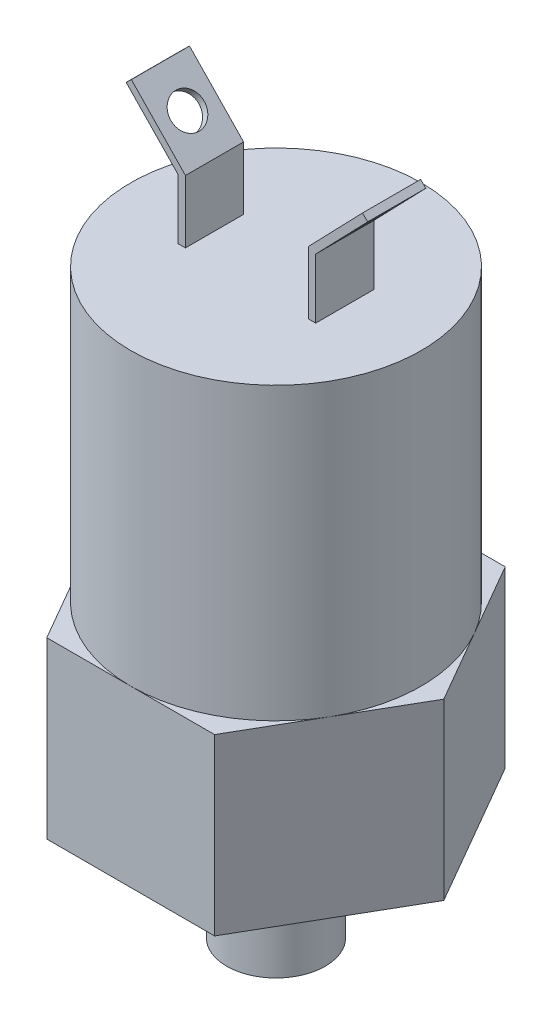
from build123d import *

# Parameters (mm, degrees)
BOSS_EXTRUDE1_DEPTH = 15.24
SKETCH3_R           = 12.7
BOSS_EXTRUDE2_DEPTH = 25.4
SKETCH4_R           = 4.3053
BOSS_EXTRUDE3_DEPTH = 10.16
EXTRUDE_THIN1_DEPTH = 2.54
CUT_EXTRUDE1_REACH  = 50.698
SKETCH6_R           = 1.4605


with BuildPart() as part:
    # Sketch2 → Boss-Extrude1 (new body)
    with BuildSketch(Plane(origin=(0, 0, 0), x_dir=(1, 0, 0), z_dir=(0, 1, 0))):
        Polygon((7.332348419, 12.7), (-7.332348419, 12.7), (-14.664696837, 0), (-7.332348419, -12.7), (7.332348419, -12.7), (14.664696837, 0), align=None)
    extrude(amount=BOSS_EXTRUDE1_DEPTH)

    # Sketch3 → Boss-Extrude2 (add)
    with BuildSketch(Plane(origin=(0, 15.24, 0), x_dir=(1, 0, 0), z_dir=(0, 1, 0))):
        Circle(SKETCH3_R)
    extrude(amount=BOSS_EXTRUDE2_DEPTH)

    # Sketch4 → Boss-Extrude3 (add)
    with BuildSketch(Plane.XZ):
        Circle(SKETCH4_R)
    extrude(amount=BOSS_EXTRUDE3_DEPTH)

    # Sketch5 → Extrude-Thin1 (add, symmetric)
    with BuildSketch(Plane.XY):
        Polygon((6.008182396, 40.64), (6.008182396, 45.866997676), (10.555270964, 50.579540341), (10.098307994, 51.020459659), (5.373182396, 46.123401761), (5.373182396, 40.64), align=None)
    extrude_thin1 = extrude(amount=EXTRUDE_THIN1_DEPTH, both=True)

    # Sketch6 → Cut-Extrude1 (cut, up to next)
    with BuildSketch(Plane(origin=(-20.264409117, 19.552939797, 0), x_dir=(0, 0, 1), z_dir=(-0.7196267237821845, 0.6943611296857851, 0)), mode=Mode.PRIVATE) as cut_extrude1_sk1:
        with Locations((0, 40.325060137)):
            Circle(SKETCH6_R)
    cut_extrude1_tool1 = extrude(cut_extrude1_sk1.sketch, amount=-CUT_EXTRUDE1_REACH, mode=Mode.PRIVATE) & part.part
    cut_extrude1 = cut_extrude1_tool1.solids().sort_by_distance((7.735745, 48.571931, 0))[0]
    add(cut_extrude1, mode=Mode.SUBTRACT)

    # Mirror1: Extrude-Thin1, Cut-Extrude1 across plane
    add(extrude_thin1.mirror(Plane(origin=(0, 0, 0), x_dir=(0, 0, 1), z_dir=(1, 0, 0))))
    add(cut_extrude1.mirror(Plane(origin=(0, 0, 0), x_dir=(0, 0, 1), z_dir=(1, 0, 0))), mode=Mode.SUBTRACT)


solid = part.part
